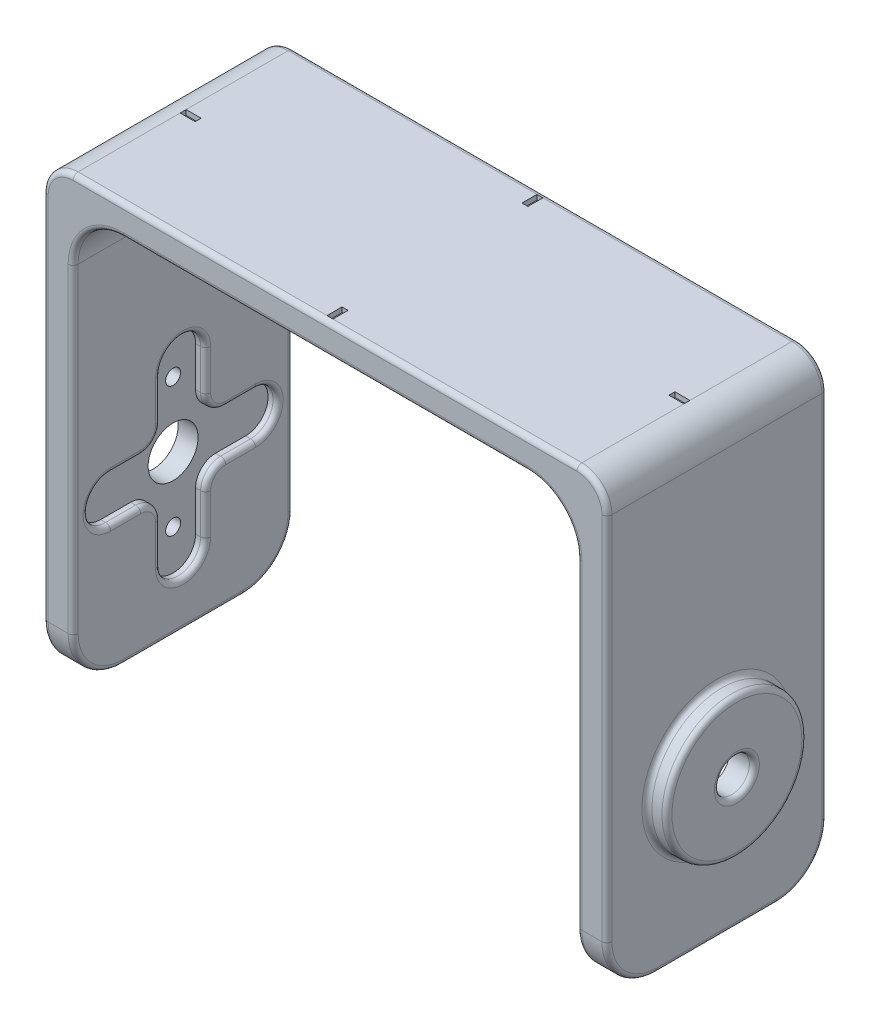
from build123d import *

# Parameters (mm, degrees)
SKETCH1_W           = 22
SKETCH1_H           = 45
BOSS_EXTRUDE1_DEPTH = 3
SKETCH2_W           = 22
SKETCH2_H           = 3
BOSS_EXTRUDE2_DEPTH = 50.4
SKETCH3_W           = 22
SKETCH3_H           = 45
BOSS_EXTRUDE3_DEPTH = 3
CUT_EXTRUDE1_DEPTH  = 1
SKETCH5_R           = 2.5
SKETCH5_R_2         = 0.75
CUT_EXTRUDE2_DEPTH  = 2
SKETCH7_R           = 5.25
CUT_EXTRUDE3_DEPTH  = 2.5
SKETCH8_R           = 7
BOSS_EXTRUDE4_DEPTH = 2
CUT_EXTRUDE4_REACH  = 60.4
SKETCH9_R           = 1.75
FILLET1_R           = 5
FILLET2_R           = 5
FILLET3_R           = 3
FILLET4_R           = 0.5
FILLET5_R           = 0.5
SKETCH10_W          = 0.6
SKETCH10_H          = 1.5
SKETCH10_W_2        = 1.5
SKETCH10_H_2        = 0.6
CUT_EXTRUDE5_DEPTH  = 0.5


with BuildPart() as part:
    # Sketch1 → Boss-Extrude1 (new body)
    with BuildSketch(Plane(origin=(0, 0, 0), x_dir=(0, 0, -1), z_dir=(1, 0, 0))):
        with Locations((11, 22.5)):
            Rectangle(SKETCH1_W, SKETCH1_H)
    extrude(amount=BOSS_EXTRUDE1_DEPTH)

    # Sketch2 → Boss-Extrude2 (add)
    with BuildSketch(Plane(origin=(3, 0, 0), x_dir=(0, 0, -1), z_dir=(1, 0, 0))):
        with Locations((11, 43.5)):
            Rectangle(SKETCH2_W, SKETCH2_H)
    extrude(amount=BOSS_EXTRUDE2_DEPTH)

    # Sketch3 → Boss-Extrude3 (add)
    with BuildSketch(Plane(origin=(53.4, 0, 0), x_dir=(0, 0, -1), z_dir=(1, 0, 0))):
        with Locations((11, 22.5)):
            Rectangle(SKETCH3_W, SKETCH3_H)
    extrude(amount=BOSS_EXTRUDE3_DEPTH)

    # Sketch4 → Cut-Extrude1 (cut)
    with BuildSketch(Plane(origin=(3, 0, 0), x_dir=(0, 0, -1), z_dir=(1, 0, 0))):
        with BuildLine():
            Line((8.75, 19.25), (8.75, 23.25))
            ThreePointArc((8.75, 23.25), (11, 25.5), (13.25, 23.25))
            Line((13.25, 23.25), (13.25, 19.25))
            ThreePointArc((13.25, 19.25), (13.835786438, 17.835786438), (15.25, 17.25))
            Line((15.25, 17.25), (18.25, 17.25))
            ThreePointArc((18.25, 17.25), (20.5, 15), (18.25, 12.75))
            Line((18.25, 12.75), (15.25, 12.75))
            ThreePointArc((15.25, 12.75), (13.835786438, 12.164213562), (13.25, 10.75))
            Line((13.25, 10.75), (13.25, 6.75))
            ThreePointArc((13.25, 6.75), (11, 4.5), (8.75, 6.75))
            Line((8.75, 6.75), (8.75, 10.75))
            ThreePointArc((8.75, 10.75), (8.164213562, 12.164213562), (6.75, 12.75))
            Line((6.75, 12.75), (3.75, 12.75))
            ThreePointArc((3.75, 12.75), (1.5, 15), (3.75, 17.25))
            Line((3.75, 17.25), (6.75, 17.25))
            ThreePointArc((6.75, 17.25), (8.164213562, 17.835786438), (8.75, 19.25))
        make_face()
    extrude(amount=-CUT_EXTRUDE1_DEPTH, mode=Mode.SUBTRACT)

    # Sketch5 → Cut-Extrude2 (cut)
    with BuildSketch(Plane(origin=(2, 0, 0), x_dir=(0, 0, -1), z_dir=(1, 0, 0))):
        with Locations((11, 15)):
            Circle(SKETCH5_R)
        with Locations((11, 21.5)):
            Circle(SKETCH5_R_2)
        with Locations((11, 8.5)):
            Circle(SKETCH5_R_2)
    extrude(amount=-CUT_EXTRUDE2_DEPTH, mode=Mode.SUBTRACT)

    # Sketch7 → Cut-Extrude3 (cut)
    with BuildSketch(Plane.ZY.offset(-53.4)):
        with Locations((-11, 15)):
            Circle(SKETCH7_R)
    extrude(amount=-CUT_EXTRUDE3_DEPTH, mode=Mode.SUBTRACT)

    # Sketch8 → Boss-Extrude4 (add)
    with BuildSketch(Plane(origin=(56.4, 0, 0), x_dir=(0, 0, -1), z_dir=(1, 0, 0))):
        with Locations((11, 15)):
            Circle(SKETCH8_R)
    extrude(amount=BOSS_EXTRUDE4_DEPTH)

    # Sketch9 → Cut-Extrude4 (cut, up to next)
    with BuildSketch(Plane(origin=(58.4, 0, 0), x_dir=(0, 0, -1), z_dir=(1, 0, 0)), mode=Mode.PRIVATE) as cut_extrude4_sk1:
        with Locations((11, 15)):
            Circle(SKETCH9_R)
    cut_extrude4_tool1 = extrude(cut_extrude4_sk1.sketch, amount=-CUT_EXTRUDE4_REACH, mode=Mode.PRIVATE) & part.part
    add(cut_extrude4_tool1.solids().sort_by_distance((58.4, 15, -11))[0], mode=Mode.SUBTRACT)

    # Fillet1
    fillet1_edges = [part.edges().sort_by_distance(p)[0] for p in [
        (54.9, 0, 0),
        (54.9, 0, -22),
        (1.5, 0, 0),
        (1.5, 0, -22),
    ]]
    fillet(fillet1_edges, radius=FILLET1_R)

    # Fillet2
    fillet2_edges = [part.edges().sort_by_distance(p)[0] for p in [
        (3, 42, -11),
        (53.4, 42, -11),
    ]]
    fillet(fillet2_edges, radius=FILLET2_R)

    # Fillet3
    fillet3_edges = [part.edges().sort_by_distance(p)[0] for p in [
        (56.4, 45, -11),
        (0, 45, -11),
    ]]
    fillet(fillet3_edges, radius=FILLET3_R)

    # Fillet4
    fillet4_edges = [part.edges().sort_by_distance(p)[0] for p in [
        (56.4, 15, -4),
        (58.4, 15, -4),
        (58.4, 15, -9.25),
        (0, 23.5, -22),
        (56.4, 23.5, -22),
        (53.4, 21, -22),
        (3, 21, -22),
        (0, 23.5, 0),
        (0, 0, -11),
        (0, 1.464466094, -1.464466094),
        (0, 1.464466094, -20.535533906),
        (3, 0, -11),
        (3, 21, 0),
        (3, 1.464466094, -1.464466094),
        (3, 1.464466094, -20.535533906),
        (53.4, 0, -11),
        (56.4, 0, -11),
        (53.4, 1.464466094, -20.535533906),
        (53.4, 1.464466094, -1.464466094),
        (56.4, 1.464466094, -20.535533906),
        (56.4, 1.464466094, -1.464466094),
        (28.2, 42, -22),
        (28.2, 42, 0),
        (53.4, 21, 0),
        (4.464466094, 40.535533906, -22),
        (4.464466094, 40.535533906, 0),
        (51.935533906, 40.535533906, -22),
        (51.935533906, 40.535533906, 0),
        (28.2, 45, -22),
        (55.521320344, 44.121320344, -22),
        (0.878679656, 44.121320344, -22),
        (28.2, 45, 0),
        (56.4, 23.5, 0),
        (55.521320344, 44.121320344, 0),
        (0.878679656, 44.121320344, 0),
        (53.4, 15, -16.25),
    ]]
    fillet(fillet4_edges, radius=FILLET4_R)

    # Fillet5
    fillet5_edges = [part.edges().sort_by_distance(p)[0] for p in [
        (3, 25.5, -11),
        (3, 21.25, -8.75),
        (3, 17.835786438, -8.164213562),
        (3, 17.25, -5.25),
        (3, 15, -1.5),
        (3, 12.75, -5.25),
        (3, 12.164213562, -8.164213562),
        (3, 8.75, -8.75),
        (3, 4.5, -11),
        (3, 8.75, -13.25),
        (3, 12.164213562, -13.835786438),
        (3, 12.75, -16.75),
        (3, 15, -20.5),
        (3, 17.25, -16.75),
        (3, 17.835786438, -13.835786438),
        (3, 21.25, -13.25),
    ]]
    fillet(fillet5_edges, radius=FILLET5_R)

    # Sketch10 → Cut-Extrude5 (cut)
    with BuildSketch(Plane(origin=(0, 45, 0), x_dir=(1, 0, 0), z_dir=(0, 1, 0))):
        with Locations((28.2, 20.75)):
            Rectangle(SKETCH10_W, SKETCH10_H)
        with Locations((28.2, 1.25)):
            Rectangle(SKETCH10_W, SKETCH10_H)
        with Locations((3.75, 11)):
            Rectangle(SKETCH10_W_2, SKETCH10_H_2)
        with Locations((52.65, 11)):
            Rectangle(SKETCH10_W_2, SKETCH10_H_2)
    extrude(amount=-CUT_EXTRUDE5_DEPTH, mode=Mode.SUBTRACT)


solid = part.part
